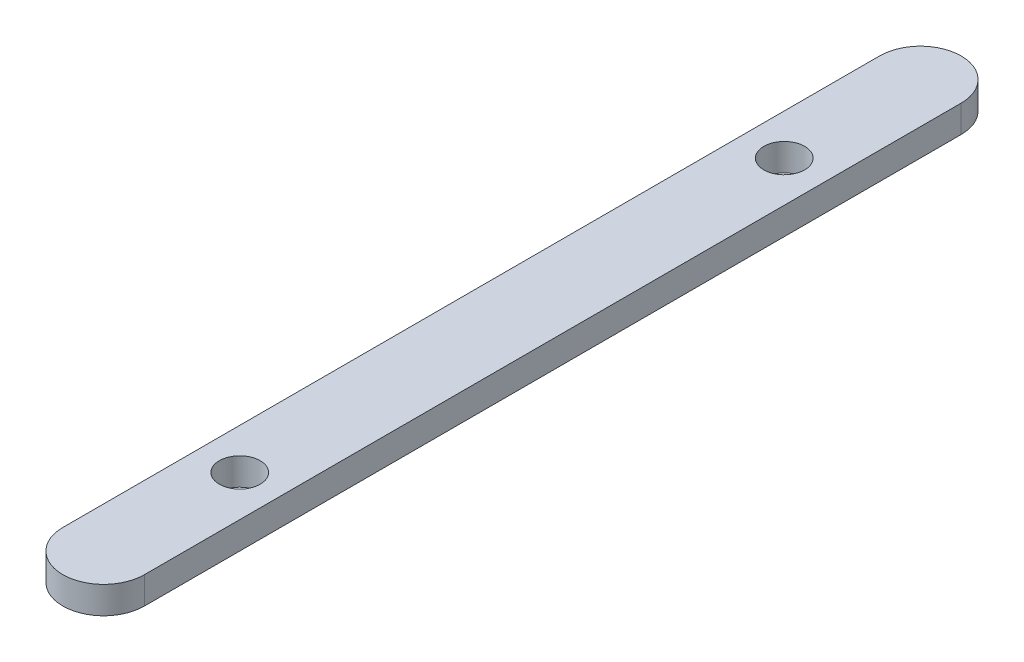
from build123d import *

# Parameters (mm, degrees)
SKETCH1_W           = 6
SKETCH1_H           = 60
SKETCH1_R           = 1.5
BOSS_EXTRUDE1_DEPTH = 2


with BuildPart() as part:
    # Sketch1 → Boss-Extrude1 (new body)
    with BuildSketch(Plane(origin=(0, 0, 0), x_dir=(1, 0, 0), z_dir=(0, 1, 0))):
        Rectangle(SKETCH1_W, SKETCH1_H)
        with Locations((0, -20)):
            Circle(SKETCH1_R, mode=Mode.SUBTRACT)
        with Locations((0, 20)):
            Circle(SKETCH1_R, mode=Mode.SUBTRACT)
        with BuildLine():
            Line((-3, -30), (3, -30))
            ThreePointArc((3, -30), (0, -33), (-3, -30))
        make_face()
        with BuildLine():
            ThreePointArc((-3, 30), (0, 33), (3, 30))
            Line((3, 30), (-3, 30))
        make_face()
    extrude(amount=BOSS_EXTRUDE1_DEPTH)


solid = part.part
